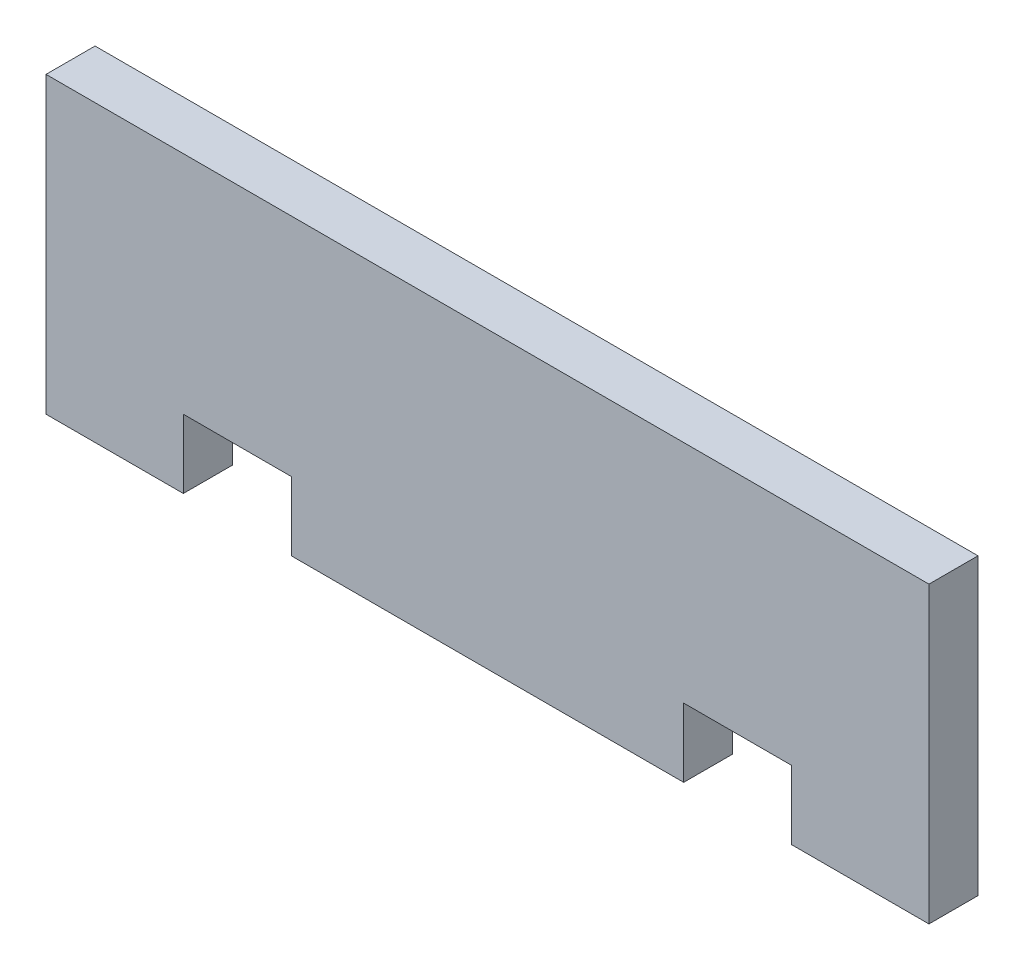
from build123d import *

# Parameters (mm, degrees)
BOSS_EXTRUDE1_DEPTH                 = 6.35
F_9_64_0_14063_DIAMETER_HOLE1_D     = 3.572002
F_9_64_0_14063_DIAMETER_HOLE1_DEPTH = 12.7
F_9_64_0_14063_DIAMETER_HOLE1_TIP   = 1.073137666


with BuildPart() as part:
    # Sketch1 → Boss-Extrude1 (new body)
    with BuildSketch(Plane.XY):
        Polygon((-39.37, 8.89), (-39.37, 0), (-57.15, 0), (-57.15, 38.1), (57.15, 38.1), (57.15, 0), (39.37, 0), (39.37, 8.89), (25.4, 8.89), (25.4, 0), (-25.4, 0), (-25.4, 8.89), align=None)
    extrude(amount=BOSS_EXTRUDE1_DEPTH)

    # 9/64 (0.14063) Diameter Hole1
    with Locations(Plane.XZ.offset(-8.89)):
        with Locations((-32.766, 3.175), (32.766, 3.175)):
            Hole(F_9_64_0_14063_DIAMETER_HOLE1_D / 2, depth=F_9_64_0_14063_DIAMETER_HOLE1_DEPTH)
            with Locations((0, 0, -(F_9_64_0_14063_DIAMETER_HOLE1_DEPTH + F_9_64_0_14063_DIAMETER_HOLE1_TIP / 2))):  # 118° drill point
                Cone(0, F_9_64_0_14063_DIAMETER_HOLE1_D / 2, F_9_64_0_14063_DIAMETER_HOLE1_TIP, mode=Mode.SUBTRACT)


solid = part.part
